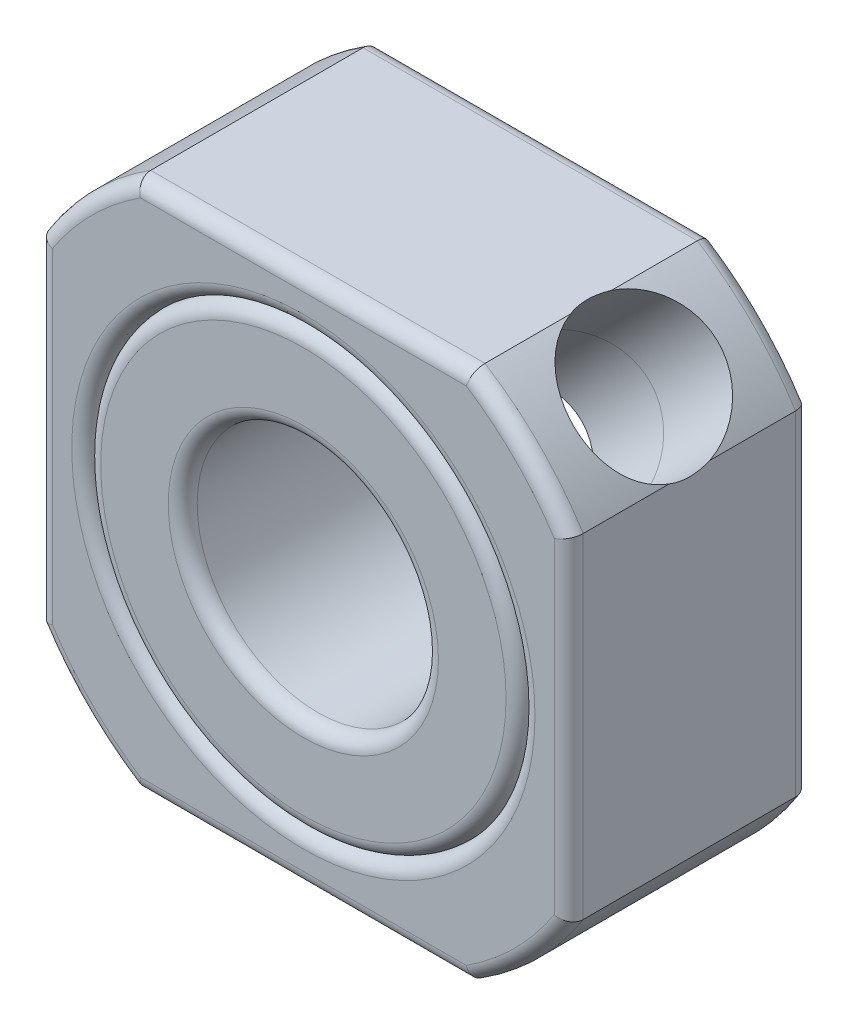
from build123d import *

# Parameters (mm, degrees)
SKETCH1_W           = 11
SKETCH1_H           = 11
BOSS_EXTRUDE1_DEPTH = 5
SKETCH2_OUTSIDE_W   = 16.268
SKETCH2_OUTSIDE_H   = 16.268
SKETCH2_OUTSIDE_R   = 6.5
CUT_EXTRUDE2_DEPTH  = 5
SKETCH3_R           = 4.5
CUT_EXTRUDE3_DEPTH  = 5
SKETCH4_R           = 4.5
SKETCH4_R_2         = 2.5
BOSS_EXTRUDE2_DEPTH = 5
FILLET1_R           = 0.3
FILLET2_R           = 0.3
SKETCH5_R           = 1.5
CUT_EXTRUDE4_DEPTH  = 8


with BuildPart() as part:
    # Sketch1 → Boss-Extrude1 (new body)
    with BuildSketch(Plane.XY):
        Rectangle(SKETCH1_W, SKETCH1_H)
    extrude(amount=-BOSS_EXTRUDE1_DEPTH)

    # Sketch2 outside → Cut-Extrude2 (cut)
    with BuildSketch(Plane.XY):
        Rectangle(SKETCH2_OUTSIDE_W, SKETCH2_OUTSIDE_H)
        Circle(SKETCH2_OUTSIDE_R, mode=Mode.SUBTRACT)
    extrude(amount=-CUT_EXTRUDE2_DEPTH, mode=Mode.SUBTRACT)

    # Sketch3 → Cut-Extrude3 (cut)
    with BuildSketch(Plane.XY):
        Circle(SKETCH3_R)
    extrude(amount=-CUT_EXTRUDE3_DEPTH, mode=Mode.SUBTRACT)

    # Fillet1
    fillet1_edges = [part.edges().sort_by_distance(p)[0] for p in [
        (-5.5, 0, 0),
        (0, -5.5, 0),
        (5.5, 0, 0),
        (0, 5.5, 0),
        (4.596194078, -4.596194078, 0),
        (-4.596194078, -4.596194078, 0),
        (-4.596194078, 4.596194078, 0),
        (-5.5, 0, -5),
        (0, 5.5, -5),
        (5.5, 0, -5),
        (0, -5.5, -5),
        (-4.596194078, 4.596194078, -5),
        (4.596194078, 4.596194078, -5),
        (4.596194078, -4.596194078, -5),
        (4.596194078, 4.596194078, 0),
        (-4.596194078, -4.596194078, -5),
        (-4.5, 0, -5),
        (-4.5, 0, 0),
    ]]
    fillet(fillet1_edges, radius=FILLET1_R)


with BuildPart() as body_2:
    # Sketch4 → Boss-Extrude2 (new body)
    with BuildSketch(Plane.XY):
        Circle(SKETCH4_R)
        Circle(SKETCH4_R_2, mode=Mode.SUBTRACT)
    extrude(amount=-BOSS_EXTRUDE2_DEPTH)

    # Fillet2
    fillet2_edges = [body_2.edges().sort_by_distance(p)[0] for p in [
        (-4.5, 0, 0),
        (-4.5, 0, -5),
        (-2.5, 0, -5),
        (-2.5, 0, 0),
    ]]
    fillet(fillet2_edges, radius=FILLET2_R)


with BuildPart() as cut_extrude4_tool:
    # Sketch5 → Cut-Extrude4 (new body)
    with BuildSketch(Plane(origin=(4.596194078, 4.596194078, 0), x_dir=(0, 0, 1), z_dir=(0.707106781, 0.707106781, 0))):
        with Locations((-2.5, 0)):
            Circle(SKETCH5_R)
    extrude(amount=-CUT_EXTRUDE4_DEPTH)


with BuildPart() as part_1:
    add(part.part)

    # Cut-Extrude4: cut by cut_extrude4_tool
    add(cut_extrude4_tool.part, mode=Mode.SUBTRACT)


with BuildPart() as body_2_1:
    add(body_2.part)

    # Cut-Extrude4: cut by cut_extrude4_tool
    add(cut_extrude4_tool.part, mode=Mode.SUBTRACT)


solid = Compound([part_1.part, body_2_1.part])
